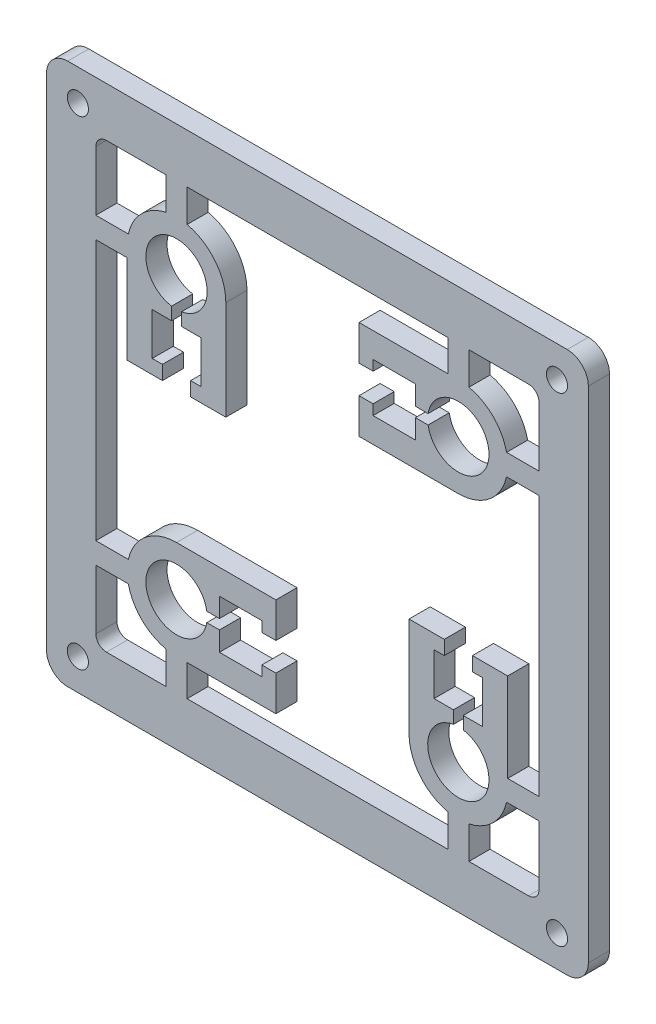
from build123d import *

# Parameters (mm, degrees)
SKETCH_1_R               = 1.5
SKETCH_1_R_2             = 4.35
EXTRUDE_1_DEPTH          = 3
EXTRUDE_3_DEPTH          = 3
CUT_EXTRUDE_2_DEPTH      = 55.459204915
PATTERN_CIRCULAR_2_COUNT = 4


with BuildPart() as part:
    # 草圖1 → 填料-伸長1 (new body)
    with BuildSketch(Plane.XY):
        with BuildLine():
            Line((35.45, 38.45), (-35.45, 38.45))
            ThreePointArc((-35.45, 38.45), (-37.571320344, 37.571320344), (-38.45, 35.45))
            Line((-38.45, 35.45), (-38.45, -35.45))
            ThreePointArc((-38.45, -35.45), (-37.571320344, -37.571320344), (-35.45, -38.45))
            Line((-35.45, -38.45), (35.45, -38.45))
            ThreePointArc((35.45, -38.45), (37.571320344, -37.571320344), (38.45, -35.45))
            Line((38.45, -35.45), (38.45, 35.45))
            ThreePointArc((38.45, 35.45), (37.571320344, 37.571320344), (35.45, 38.45))
        make_face()
        with Locations((-34, -34)):
            Circle(SKETCH_1_R, mode=Mode.SUBTRACT)
        with BuildLine():
            Line((-21.5, -31.45), (-29.95, -31.45))
            ThreePointArc((-29.95, -31.45), (-31.010660172, -31.010660172), (-31.45, -29.95))
            Line((-31.45, -29.95), (-31.45, -21.5))
            Line((-31.45, -21.5), (-26.837397166, -21.5))
            ThreePointArc((-26.837397166, -21.5), (-24.949747468, -24.949747468), (-21.5, -26.837397166))
            Line((-21.5, -26.837397166), (-21.5, -31.45))
        make_face(mode=Mode.SUBTRACT)
        with Locations((-20, -20)):
            Circle(SKETCH_1_R_2, mode=Mode.SUBTRACT)
        with BuildLine():
            Line((18.5, -31.45), (-18.5, -31.45))
            Line((-18.5, -31.45), (-18.5, -26.837397166))
            ThreePointArc((-18.5, -26.837397166), (-15.050252532, -24.949747468), (-13.162602834, -21.5))
            Line((-13.162602834, -21.5), (13.162602834, -21.5))
            ThreePointArc((13.162602834, -21.5), (15.050252532, -24.949747468), (18.5, -26.837397166))
            Line((18.5, -26.837397166), (18.5, -31.45))
        make_face(mode=Mode.SUBTRACT)
        with Locations((34, -34)):
            Circle(SKETCH_1_R, mode=Mode.SUBTRACT)
        with BuildLine():
            Line((21.5, -31.45), (21.5, -26.837397166))
            ThreePointArc((21.5, -26.837397166), (24.949747468, -24.949747468), (26.837397166, -21.5))
            Line((26.837397166, -21.5), (31.45, -21.5))
            Line((31.45, -21.5), (31.45, -29.95))
            ThreePointArc((31.45, -29.95), (31.010660172, -31.010660172), (29.95, -31.45))
            Line((29.95, -31.45), (21.5, -31.45))
        make_face(mode=Mode.SUBTRACT)
        with Locations((20, -20)):
            Circle(SKETCH_1_R_2, mode=Mode.SUBTRACT)
        with BuildLine():
            Line((-31.45, -18.5), (-31.45, 18.5))
            Line((-31.45, 18.5), (-26.837397166, 18.5))
            ThreePointArc((-26.837397166, 18.5), (-24.949747468, 15.050252532), (-21.5, 13.162602834))
            Line((-21.5, 13.162602834), (-21.5, -13.162602834))
            ThreePointArc((-21.5, -13.162602834), (-24.949747468, -15.050252532), (-26.837397166, -18.5))
            Line((-26.837397166, -18.5), (-31.45, -18.5))
        make_face(mode=Mode.SUBTRACT)
        with Locations((-20, 20)):
            Circle(SKETCH_1_R_2, mode=Mode.SUBTRACT)
        with BuildLine():
            ThreePointArc((-31.45, 29.95), (-31.010660172, 31.010660172), (-29.95, 31.45))
            Line((-29.95, 31.45), (-21.5, 31.45))
            Line((-21.5, 31.45), (-21.5, 26.837397166))
            ThreePointArc((-21.5, 26.837397166), (-24.949747468, 24.949747468), (-26.837397166, 21.5))
            Line((-26.837397166, 21.5), (-31.45, 21.5))
            Line((-31.45, 21.5), (-31.45, 29.95))
        make_face(mode=Mode.SUBTRACT)
        with Locations((-34, 34)):
            Circle(SKETCH_1_R, mode=Mode.SUBTRACT)
        with BuildLine():
            ThreePointArc((-18.5, 13.162602834), (-15.050252532, 15.050252532), (-13.162602834, 18.5))
            Line((-13.162602834, 18.5), (13.162602834, 18.5))
            ThreePointArc((13.162602834, 18.5), (15.050252532, 15.050252532), (18.5, 13.162602834))
            Line((18.5, 13.162602834), (18.5, -13.162602834))
            ThreePointArc((18.5, -13.162602834), (15.050252532, -15.050252532), (13.162602834, -18.5))
            Line((13.162602834, -18.5), (-13.162602834, -18.5))
            ThreePointArc((-13.162602834, -18.5), (-15.050252532, -15.050252532), (-18.5, -13.162602834))
            Line((-18.5, -13.162602834), (-18.5, 13.162602834))
        make_face(mode=Mode.SUBTRACT)
        with BuildLine():
            ThreePointArc((21.5, 13.162602834), (24.949747468, 15.050252532), (26.837397166, 18.5))
            Line((26.837397166, 18.5), (31.45, 18.5))
            Line((31.45, 18.5), (31.45, -18.5))
            Line((31.45, -18.5), (26.837397166, -18.5))
            ThreePointArc((26.837397166, -18.5), (24.949747468, -15.050252532), (21.5, -13.162602834))
            Line((21.5, -13.162602834), (21.5, 13.162602834))
        make_face(mode=Mode.SUBTRACT)
        with BuildLine():
            Line((-18.5, 26.837397166), (-18.5, 31.45))
            Line((-18.5, 31.45), (18.5, 31.45))
            Line((18.5, 31.45), (18.5, 26.837397166))
            ThreePointArc((18.5, 26.837397166), (15.050252532, 24.949747468), (13.162602834, 21.5))
            Line((13.162602834, 21.5), (-13.162602834, 21.5))
            ThreePointArc((-13.162602834, 21.5), (-15.050252532, 24.949747468), (-18.5, 26.837397166))
        make_face(mode=Mode.SUBTRACT)
        with Locations((20, 20)):
            Circle(SKETCH_1_R_2, mode=Mode.SUBTRACT)
        with BuildLine():
            ThreePointArc((29.95, 31.45), (31.010660172, 31.010660172), (31.45, 29.95))
            Line((31.45, 29.95), (31.45, 21.5))
            Line((31.45, 21.5), (26.837397166, 21.5))
            ThreePointArc((26.837397166, 21.5), (24.949747468, 24.949747468), (21.5, 26.837397166))
            Line((21.5, 26.837397166), (21.5, 31.45))
            Line((21.5, 31.45), (29.95, 31.45))
        make_face(mode=Mode.SUBTRACT)
        with Locations((34, 34)):
            Circle(SKETCH_1_R, mode=Mode.SUBTRACT)
    extrude(amount=EXTRUDE_1_DEPTH)

    # 草圖2 → 填料-伸長3 (add)
    with BuildSketch(Plane(origin=(0, 0, 0), x_dir=(-1, 0, 0), z_dir=(0, 0, -1))):
        with BuildLine():
            ThreePointArc((16.55, 13.909228292), (13.952273154, 16.475088654), (13, 20))
            Line((13, 20), (13, 5.9))
            Line((13, 5.9), (15.009228292, 3.9))
            Line((15.009228292, 3.9), (24.990771708, 3.9))
            Line((24.990771708, 3.9), (27, 5.9))
            Line((27, 5.9), (27, 20))
            ThreePointArc((27, 20), (26.047726846, 16.475088654), (23.45, 13.909228292))
            Line((23.45, 13.909228292), (23.45, 7.9))
            Line((23.45, 7.9), (16.55, 7.9))
            Line((16.55, 7.9), (16.55, 13.909228292))
        make_face()
    extrude_3 = extrude(amount=-EXTRUDE_3_DEPTH)

    # 草圖4 → 除料-伸長2 (cut, through all)
    with BuildSketch(Plane(origin=(0, 0, 0), x_dir=(-1, 0, 0), z_dir=(0, 0, -1))):
        with BuildLine():
            Line((16.55, 13.909228292), (16.55, 7.899228292))
            Line((16.55, 7.899228292), (18, 7.899228292))
            Line((18, 7.899228292), (18, 5.9))
            Line((18, 5.9), (13, 5.9))
            Line((13, 5.9), (13, -2.100771708))
            Line((13, -2.100771708), (18.5, -2.100771708))
            Line((18.5, -2.100771708), (18.5, -13))
            Line((18.5, -13), (20, -13))
            ThreePointArc((20, -13), (20.754393744, -13.040769433), (21.5, -13.162602834))
            Line((21.5, -13.162602834), (21.5, -2.100771708))
            Line((21.5, -2.100771708), (31.45, -2.100771708))
            Line((31.45, -2.100771708), (31.45, 5.9))
            Line((31.45, 5.9), (22, 5.9))
            Line((22, 5.9), (22, 7.899228292))
            Line((22, 7.899228292), (23.45, 7.899228292))
            Line((23.45, 7.899228292), (23.45, 13.909228292))
            Line((23.45, 13.909228292), (20.7, 13.909228292))
            Line((20.7, 13.909228292), (20.7, 16.409228292))
            Line((20.7, 16.409228292), (19.3, 16.409228292))
            Line((19.3, 16.409228292), (19.3, 13.909228292))
            Line((19.3, 13.909228292), (16.55, 13.909228292))
        make_face()
    cut_extrude_2 = extrude(amount=-CUT_EXTRUDE_2_DEPTH, mode=Mode.SUBTRACT)

    # 環狀複製排列2: 填料-伸長3, 除料-伸長2 ×4 about axis
    pattern_circular_2_axis = Axis((0, 0, -0.15), (0, 0, 1))
    add([extrude_3.rotate(pattern_circular_2_axis, i * 360 / PATTERN_CIRCULAR_2_COUNT) for i in range(1, PATTERN_CIRCULAR_2_COUNT)])
    add([cut_extrude_2.rotate(pattern_circular_2_axis, i * 360 / PATTERN_CIRCULAR_2_COUNT) for i in range(1, PATTERN_CIRCULAR_2_COUNT)], mode=Mode.SUBTRACT)


solid = part.part
